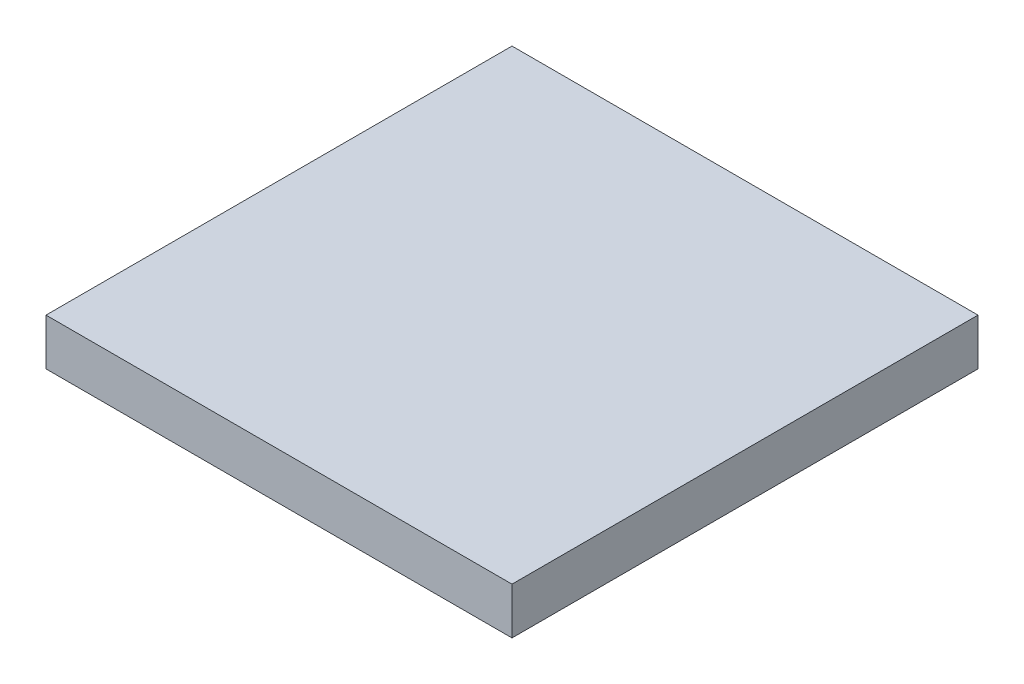
from build123d import *

# Parameters (mm, degrees)
SKETCH1_W           = 1000
SKETCH1_H           = 100
BOSS_EXTRUDE1_DEPTH = 1000


with BuildPart() as part:
    # Sketch1 → Boss-Extrude1 (new body)
    with BuildSketch(Plane.XY):
        Rectangle(SKETCH1_W, SKETCH1_H)
    extrude(amount=BOSS_EXTRUDE1_DEPTH)


solid = part.part
